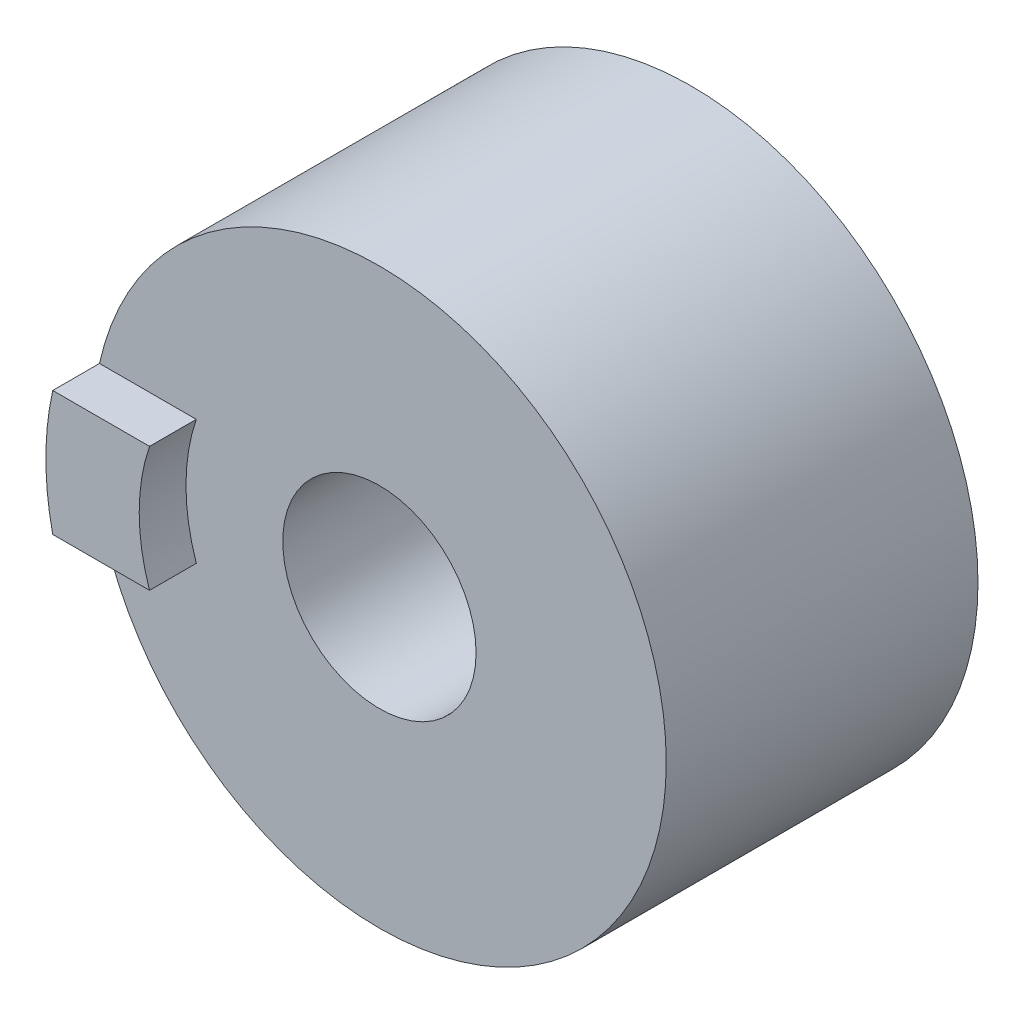
from build123d import *

# Parameters (mm, degrees)
BOSS_EXTRUDE1_DEPTH = 0.75


with BuildPart() as part:
    # Sketch1 → Revolve1 (revolve)
    with BuildSketch(Plane(origin=(0, 0, 0), x_dir=(1, 0, 0), z_dir=(0, 1, 0))):
        Polygon((3.05, 0), (0, -2), (0, -7), (3.05, -7), align=None)
    revolve(axis=Axis((4.6, 0, 0), (0, 0, 1)))

    # Sketch2 → Boss-Extrude1 (add)
    with BuildSketch(Plane.XY.offset(7)):
        with BuildLine():
            Line((0.110011136, 1), (1.6626194, 1))
            ThreePointArc((1.6626194, 1), (1.538733475, 0.506805736), (1.497065133, 0))
            ThreePointArc((1.497065133, 0), (1.538733475, -0.506805736), (1.6626194, -1))
            Line((1.6626194, -1), (0.110011136, -1))
            ThreePointArc((0.110011136, -1), (0, 0), (0.110011136, 1))
        make_face()
    extrude(amount=BOSS_EXTRUDE1_DEPTH)


solid = part.part
